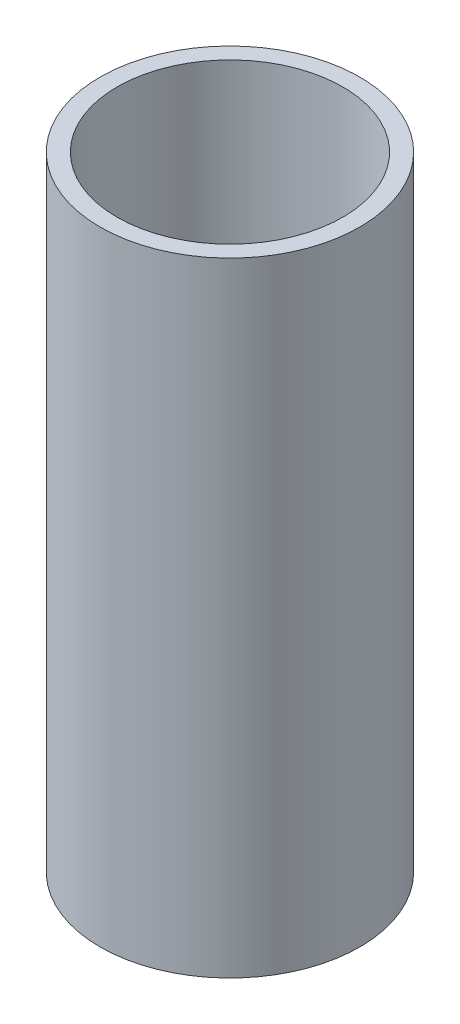
from build123d import *

# Parameters (mm, degrees)
SKETCH1_R           = 28.575
BOSS_EXTRUDE1_DEPTH = 137.16
SKETCH2_R           = 24.829267429
CUT_EXTRUDE1_DEPTH  = 76.2
SKETCH3_R           = 20
CUT_EXTRUDE2_DEPTH  = 20


with BuildPart() as part:
    # Sketch1 → Boss-Extrude1 (new body)
    with BuildSketch(Plane(origin=(0, 0, 0), x_dir=(1, 0, 0), z_dir=(0, 1, 0))):
        Circle(SKETCH1_R)
    extrude(amount=BOSS_EXTRUDE1_DEPTH)

    # Sketch2 → Cut-Extrude1 (cut)
    with BuildSketch(Plane(origin=(0, 137.16, 0), x_dir=(1, 0, 0), z_dir=(0, 1, 0))):
        Circle(SKETCH2_R)
    extrude(amount=-CUT_EXTRUDE1_DEPTH, mode=Mode.SUBTRACT)

    # Sketch3 → Cut-Extrude2 (cut)
    with BuildSketch(Plane.XZ):
        Circle(SKETCH3_R)
    extrude(amount=-CUT_EXTRUDE2_DEPTH, mode=Mode.SUBTRACT)


solid = part.part
